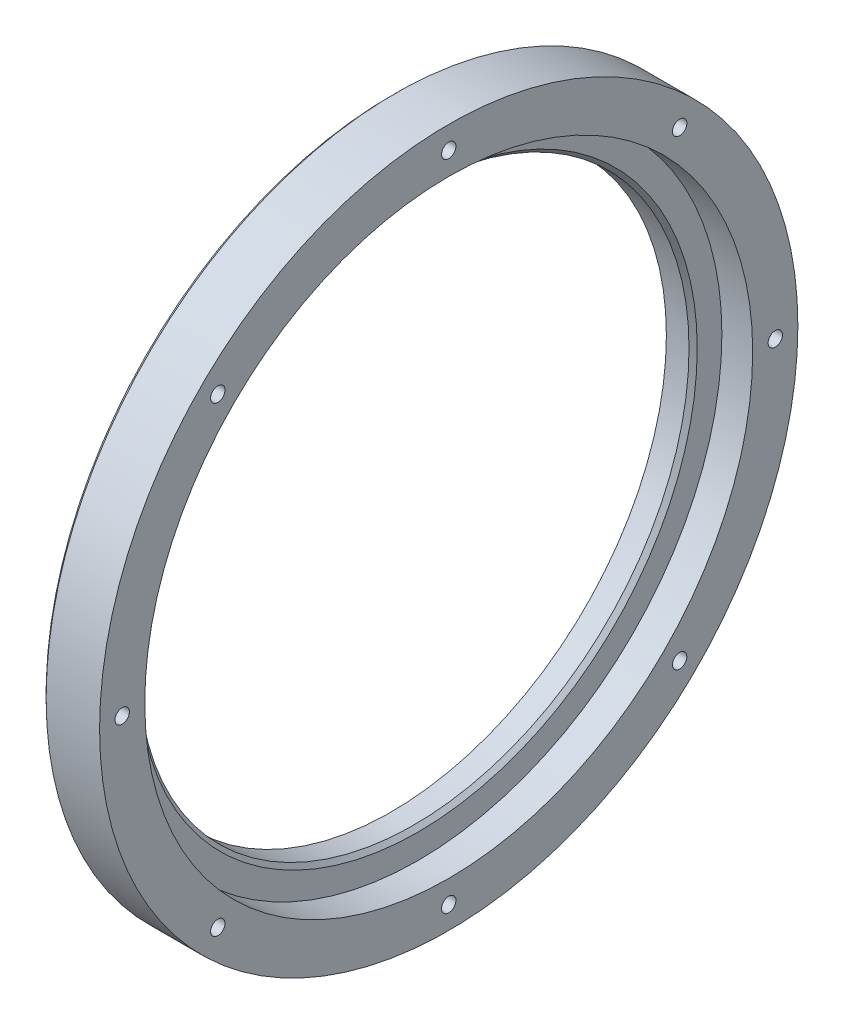
from build123d import *

# Parameters (mm, degrees)
SZKIC2_R                   = 1.75
WYTNIJ_WYCI_GNI_CIE1_DEPTH = 15.013168353
SZKIC4_R                   = 3
WYTNIJ_WYCI_GNI_CIE2_DEPTH = 4
SFAZOWANIE1_SIZE           = 1


with BuildPart() as part:
    # Szkic1 → Obrót1 (revolve)
    with BuildSketch(Plane.XY):
        Polygon((-272.858046523, 75.009269975), (-280.358046523, 75.009269975), (-280.358046523, 68.009269975), (-286.871214876, 68.009269975), (-286.871214876, 85.009269975), (-285.871214876, 86.009269975), (-272.858046523, 86.009269975), align=None)
    revolve(axis=Axis((-268.908046523, 1.009269975, 0), (-1, 0, 0)))

    # Szkic2 → Wytnij-wyciągnięcie1 (cut, through all)
    with BuildSketch(Plane.ZY.offset(286.871214876)):
        with Locations((79.5, 1.009269975)):
            Circle(SZKIC2_R)
        with Locations((56.214989104, -55.20571913)):
            Circle(SZKIC2_R)
        with Locations((0, -78.490730025)):
            Circle(SZKIC2_R)
        with Locations((-56.214989104, -55.20571913)):
            Circle(SZKIC2_R)
        with Locations((-79.5, 1.009269975)):
            Circle(SZKIC2_R)
        with Locations((-56.214989104, 57.224259079)):
            Circle(SZKIC2_R)
        with Locations((0, 80.509269975)):
            Circle(SZKIC2_R)
        with Locations((56.214989104, 57.224259079)):
            Circle(SZKIC2_R)
    extrude(amount=-WYTNIJ_WYCI_GNI_CIE1_DEPTH, mode=Mode.SUBTRACT)

    # Szkic4 → Wytnij-wyciągnięcie2 (cut)
    with BuildSketch(Plane.ZY.offset(286.871214876)):
        with Locations((79.5, 1.009269975)):
            Circle(SZKIC4_R)
        with Locations((56.214989104, -55.20571913)):
            Circle(SZKIC4_R)
        with Locations((0, -78.490730025)):
            Circle(SZKIC4_R)
        with Locations((-56.214989104, -55.20571913)):
            Circle(SZKIC4_R)
        with Locations((-79.5, 1.009269975)):
            Circle(SZKIC4_R)
        with Locations((-56.214989104, 57.224259079)):
            Circle(SZKIC4_R)
        with Locations((0, 80.509269975)):
            Circle(SZKIC4_R)
        with Locations((56.214989104, 57.224259079)):
            Circle(SZKIC4_R)
    extrude(amount=-WYTNIJ_WYCI_GNI_CIE2_DEPTH, mode=Mode.SUBTRACT)

    # Sfazowanie1
    sfazowanie1_edges = [part.edges().sort_by_distance(p)[0] for p in [
        (-280.358046523, -65.990730025, 0),
    ]]
    chamfer(sfazowanie1_edges, length=SFAZOWANIE1_SIZE)


solid = part.part
